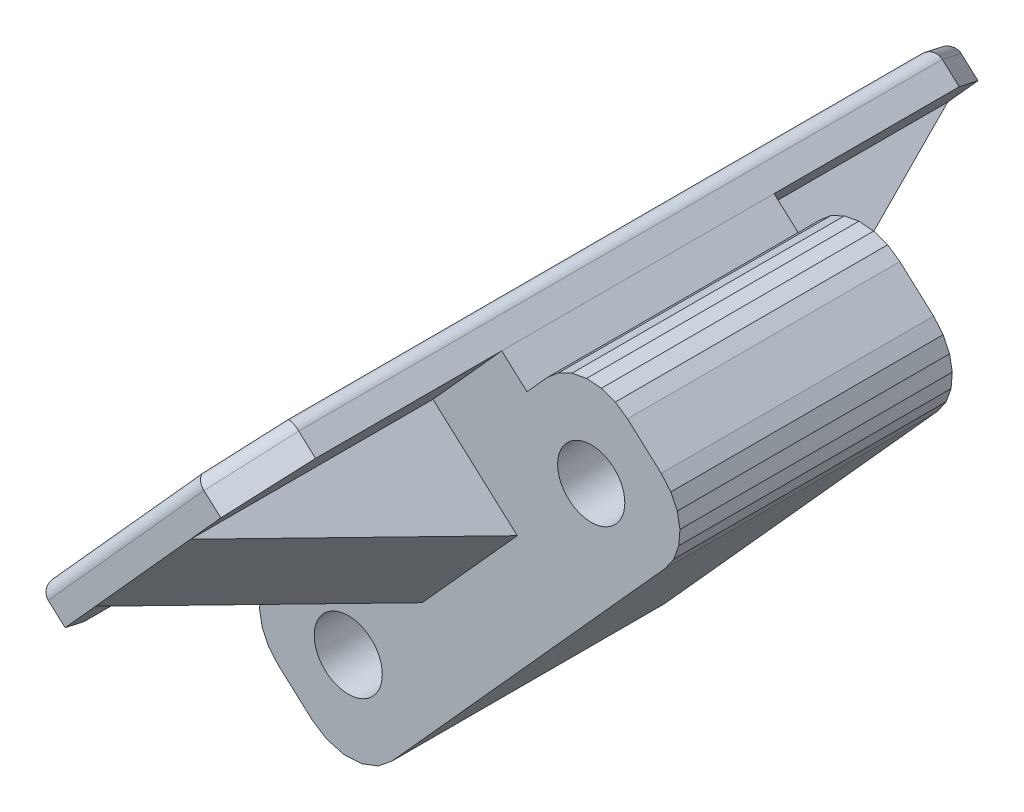
from build123d import *

# Parameters (mm, degrees)
MODEL_R             = 1.48
MODEL_R_2           = 1.5
BOSS_EXTRUDE1_DEPTH = 12
SKETCH3_W           = 12
SKETCH3_H           = 15.317128206
BOSS_EXTRUDE2_DEPTH = 1.5
BOSS_EXTRUDE3_DEPTH = 1.5
BOSS_EXTRUDE4_START = -4.5
BOSS_EXTRUDE4_DEPTH = 6.26
CHAMFER1_SIZE       = 2.5
FILLET2_R           = 0.5
CUT_EXTRUDE1_DEPTH  = 1


with BuildPart() as part:
    # Model → Boss-Extrude1 (new body)
    with BuildSketch(Plane.XY):
        Polygon((5.6444, 52.0867), (5.2748, 51.5489), (5.0569, 50.9337), (5.0057, 50.2831), (5.1246, 49.6414), (5.4056, 49.0523), (5.8295, 48.556), (7.3157, 47.2178), (7.9717, 46.7918), (8.7273, 46.5893), (9.5084, 46.6303), (10.2386, 46.9106), (10.8464, 47.4028), (22.8908, 60.7794), (23.2604, 61.3173), (23.4783, 61.9325), (23.5295, 62.5831), (23.4106, 63.2248), (23.1296, 63.8138), (22.7058, 64.3101), (21.2195, 65.6484), (20.6816, 66.018), (20.0664, 66.2359), (19.4158, 66.2871), (18.7741, 66.1681), (18.185, 65.8872), (17.6888, 65.4633), align=None)
        with Locations((19.6206, 62.3782)):
            Circle(MODEL_R, mode=Mode.SUBTRACT)
        with Locations((8.9146, 50.4879)):
            Circle(MODEL_R_2, mode=Mode.SUBTRACT)
    extrude(amount=BOSS_EXTRUDE1_DEPTH)

    # Sketch3 → Boss-Extrude2 (add)
    with BuildSketch(Plane(origin=(-22.783506803, 20.514455792, 0), x_dir=(0, 0, 1), z_dir=(-0.7431432988578212, 0.669132301837772, 0))):
        with Locations((6, 51.484746303)):
            Rectangle(SKETCH3_W, SKETCH3_H)
    extrude(amount=BOSS_EXTRUDE2_DEPTH)

    # Sketch4 → Boss-Extrude3 (add)
    with BuildSketch(Plane(origin=(-23.898221752, 21.518154244, 0), x_dir=(0, 0, 1), z_dir=(-0.7431432988578212, 0.669132301837772, 0))):
        Polygon((-10.680029898, 56.112643872), (-10.680029898, 59.112643872), (-7.680029898, 59.112643872), (19.680029898, 59.112643872), (22.680029898, 59.112643872), (22.680029898, 56.112643872), (22.680029898, 46.856848734), (22.680029898, 43.856848734), (19.680029898, 43.856848734), (-7.680029898, 43.856848734), (-10.680029898, 43.856848734), (-10.680029898, 46.856848734), align=None)
    extrude(amount=BOSS_EXTRUDE3_DEPTH)

    # Sketch9 → Boss-Extrude4 (add)
    with BuildSketch(Plane(origin=(29.346034145, 32.591923246, 0), x_dir=(0.7431432988578212, -0.669132301837772, 0), z_dir=(-0.669132301837772, -0.7431432988578212, 0)).offset(BOSS_EXTRUDE4_START)):
        Polygon((-32.15829543, 12), (-32.15829543, 22.680029898), (-27.158287979, 12), align=None)
    boss_extrude4 = extrude(amount=-BOSS_EXTRUDE4_DEPTH)

    # Mirror1: Boss-Extrude4 across plane
    add(boss_extrude4.mirror(Plane.XY.offset(6)))

    # Chamfer1
    chamfer1_edges = [part.edges().sort_by_distance(p)[0] for p in [
        (4.890454919, 54.611926717, 22.680029898),
        (4.890454919, 54.611926717, -10.680029898),
        (15.098600236, 65.949168642, -10.680029898),
        (15.098600236, 65.949168642, 22.680029898),
    ]]
    chamfer(chamfer1_edges, length=CHAMFER1_SIZE)

    # Fillet2
    fillet2_edges = [part.edges().sort_by_distance(p)[0] for p in [
        (4.333097445, 55.113775943, 6),
        (13.704827384, 65.522088744, 21.430029898),
        (9.437170103, 60.782396906, 22.680029898),
        (5.169512823, 56.042705067, 21.430029898),
        (13.704827384, 65.522088744, -9.430029898),
        (5.169512823, 56.042705067, -9.430029898),
        (9.437170103, 60.782396906, -10.680029898),
        (14.541242762, 66.451017868, 6),
    ]]
    fillet(fillet2_edges, radius=FILLET2_R)

    # Sketch10 → Cut-Extrude1 (cut)
    with BuildSketch(Plane(origin=(-25.0129367, 22.521852697, 0), x_dir=(0, 0, 1), z_dir=(-0.7431432988578214, 0.6691323018377716, 0))):
        with BuildLine():
            Line((19, 53.048695087), (-7, 53.048695087))
            ThreePointArc((-7, 53.048695087), (-9, 55.048695087), (-7, 57.048695087))
            Line((-7, 57.048695087), (19, 57.048695087))
            ThreePointArc((19, 57.048695087), (21, 55.048695087), (19, 53.048695087))
        make_face()
        with BuildLine():
            Line((19, 49.920797519), (-7, 49.920797519))
            ThreePointArc((-7, 49.920797519), (-9, 47.920797519), (-7, 45.920797519))
            Line((-7, 45.920797519), (19, 45.920797519))
            ThreePointArc((19, 45.920797519), (21, 47.920797519), (19, 49.920797519))
        make_face()
    extrude(amount=-CUT_EXTRUDE1_DEPTH, mode=Mode.SUBTRACT)


solid = part.part
